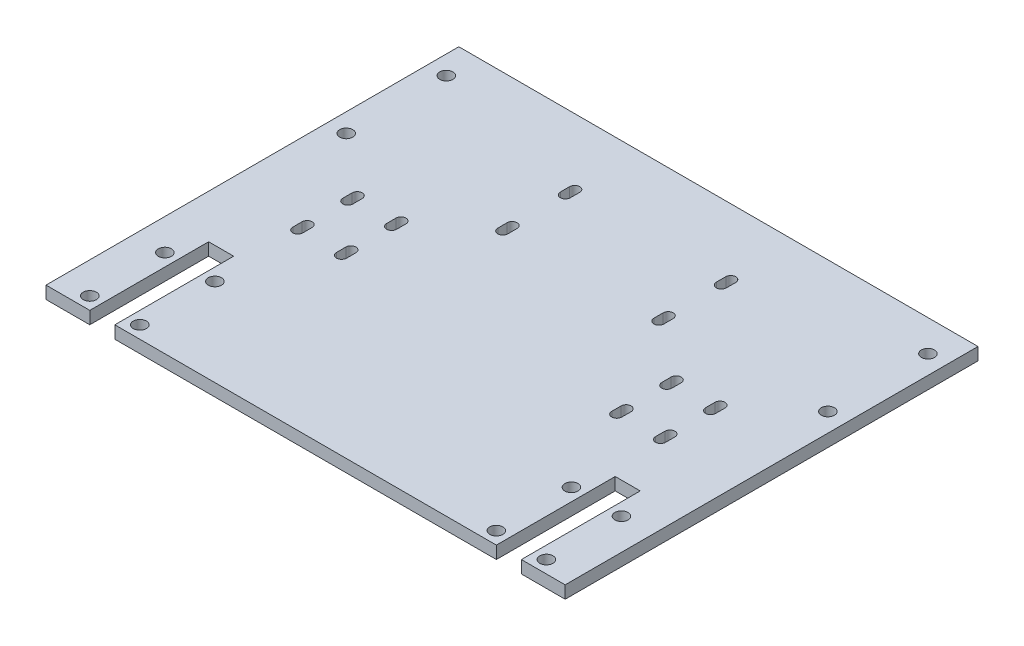
from build123d import *

# Parameters (mm, degrees)
SKETCH1_W           = 166
SKETCH1_H           = 160
SKETCH1_R           = 2.1
BOSS_EXTRUDE1_DEPTH = 4
CUT_EXTRUDE1_DEPTH  = 5
SKETCH3_R           = 2.1
SKETCH3_W           = 8
SKETCH3_H           = 44
CUT_EXTRUDE2_DEPTH  = 10
SKETCH4_W           = 166
SKETCH4_H           = 28
CUT_EXTRUDE3_DEPTH  = 10
CUT_EXTRUDE4_DEPTH  = 5


with BuildPart() as part:
    # Sketch1 → Boss-Extrude1 (new body)
    with BuildSketch(Plane(origin=(0, 0, 0), x_dir=(1, 0, 0), z_dir=(0, 1, 0))):
        Rectangle(SKETCH1_W, SKETCH1_H)
        with Locations((-77, 74)):
            Circle(SKETCH1_R, mode=Mode.SUBTRACT)
        with Locations((-77, 10)):
            Circle(SKETCH1_R, mode=Mode.SUBTRACT)
        with Locations((77, 74)):
            Circle(SKETCH1_R, mode=Mode.SUBTRACT)
        with Locations((77, 10)):
            Circle(SKETCH1_R, mode=Mode.SUBTRACT)
        with Locations((-77, 42)):
            Circle(SKETCH1_R, mode=Mode.SUBTRACT)
        with Locations((77, 42)):
            Circle(SKETCH1_R, mode=Mode.SUBTRACT)
    extrude(amount=BOSS_EXTRUDE1_DEPTH)

    # Sketch2 → Cut-Extrude1 (cut)
    with BuildSketch(Plane(origin=(0, 4, 0), x_dir=(1, 0, 0), z_dir=(0, 1, 0))):
        with BuildLine():
            Line((-59.6, -24.5), (-59.6, -21.5))
            ThreePointArc((-59.6, -21.5), (-58, -19.9), (-56.4, -21.5))
            Line((-56.4, -21.5), (-56.4, -24.5))
            ThreePointArc((-56.4, -24.5), (-58, -26.1), (-59.6, -24.5))
        make_face()
        with BuildLine():
            Line((-45.6, -24.5), (-45.6, -21.5))
            ThreePointArc((-45.6, -21.5), (-44, -19.9), (-42.4, -21.5))
            Line((-42.4, -21.5), (-42.4, -24.5))
            ThreePointArc((-42.4, -24.5), (-44, -26.1), (-45.6, -24.5))
        make_face()
        with BuildLine():
            Line((-45.6, -8.5), (-45.6, -5.5))
            ThreePointArc((-45.6, -5.5), (-44, -3.9), (-42.4, -5.5))
            Line((-42.4, -5.5), (-42.4, -8.5))
            ThreePointArc((-42.4, -8.5), (-44, -10.1), (-45.6, -8.5))
        make_face()
        with BuildLine():
            Line((-59.6, -8.5), (-59.6, -5.5))
            ThreePointArc((-59.6, -5.5), (-58, -3.9), (-56.4, -5.5))
            Line((-56.4, -5.5), (-56.4, -8.5))
            ThreePointArc((-56.4, -8.5), (-58, -10.1), (-59.6, -8.5))
        make_face()
        with BuildLine():
            Line((59.6, -8.5), (59.6, -5.5))
            ThreePointArc((59.6, -5.5), (58, -3.9), (56.4, -5.5))
            Line((56.4, -5.5), (56.4, -8.5))
            ThreePointArc((56.4, -8.5), (58, -10.1), (59.6, -8.5))
        make_face()
        with BuildLine():
            Line((45.6, -8.5), (45.6, -5.5))
            ThreePointArc((45.6, -5.5), (44, -3.9), (42.4, -5.5))
            Line((42.4, -5.5), (42.4, -8.5))
            ThreePointArc((42.4, -8.5), (44, -10.1), (45.6, -8.5))
        make_face()
        with BuildLine():
            Line((45.6, -24.5), (45.6, -21.5))
            ThreePointArc((45.6, -21.5), (44, -19.9), (42.4, -21.5))
            Line((42.4, -21.5), (42.4, -24.5))
            ThreePointArc((42.4, -24.5), (44, -26.1), (45.6, -24.5))
        make_face()
        with BuildLine():
            Line((59.6, -24.5), (59.6, -21.5))
            ThreePointArc((59.6, -21.5), (58, -19.9), (56.4, -21.5))
            Line((56.4, -21.5), (56.4, -24.5))
            ThreePointArc((56.4, -24.5), (58, -26.1), (59.6, -24.5))
        make_face()
    extrude(amount=-CUT_EXTRUDE1_DEPTH, mode=Mode.SUBTRACT)

    # Sketch3 → Cut-Extrude2 (cut)
    with BuildSketch(Plane(origin=(0, 4, 0), x_dir=(1, 0, 0), z_dir=(0, 1, 0))):
        with Locations((-73, -76)):
            Circle(SKETCH3_R)
        with Locations((-57, -76)):
            Circle(SKETCH3_R)
        with Locations((-57, -52)):
            Circle(SKETCH3_R)
        with Locations((-73, -52)):
            Circle(SKETCH3_R)
        with Locations((73, -52)):
            Circle(SKETCH3_R)
        with Locations((57, -52)):
            Circle(SKETCH3_R)
        with Locations((57, -76)):
            Circle(SKETCH3_R)
        with Locations((73, -76)):
            Circle(SKETCH3_R)
        with Locations((-65, -64)):
            Rectangle(SKETCH3_W, SKETCH3_H)
        with Locations((65, -64)):
            Rectangle(SKETCH3_W, SKETCH3_H)
    extrude(amount=-CUT_EXTRUDE2_DEPTH, mode=Mode.SUBTRACT)

    # Sketch4 → Cut-Extrude3 (cut)
    with BuildSketch(Plane(origin=(0, 4, 0), x_dir=(1, 0, 0), z_dir=(0, 1, 0))):
        with Locations((0, 66)):
            Rectangle(SKETCH4_W, SKETCH4_H)
    extrude(amount=-CUT_EXTRUDE3_DEPTH, mode=Mode.SUBTRACT)

    # Sketch5 → Cut-Extrude4 (cut, through all)
    with BuildSketch(Plane(origin=(0, 4, 0), x_dir=(1, 0, 0), z_dir=(0, 1, 0))):
        with BuildLine():
            Line((-26.55, 28), (-26.55, 31))
            ThreePointArc((-26.55, 31), (-24.95, 32.6), (-23.35, 31))
            Line((-23.35, 31), (-23.35, 28))
            ThreePointArc((-23.35, 28), (-24.95, 26.4), (-26.55, 28))
        make_face()
        with BuildLine():
            Line((23.35, 28), (23.35, 31))
            ThreePointArc((23.35, 31), (24.95, 32.6), (26.55, 31))
            Line((26.55, 31), (26.55, 28))
            ThreePointArc((26.55, 28), (24.95, 26.4), (23.35, 28))
        make_face()
        with BuildLine():
            Line((23.35, 8), (23.35, 11))
            ThreePointArc((23.35, 11), (24.95, 12.6), (26.55, 11))
            Line((26.55, 11), (26.55, 8))
            ThreePointArc((26.55, 8), (24.95, 6.4), (23.35, 8))
        make_face()
        with BuildLine():
            Line((-26.55, 8), (-26.55, 11))
            ThreePointArc((-26.55, 11), (-24.95, 12.6), (-23.35, 11))
            Line((-23.35, 11), (-23.35, 8))
            ThreePointArc((-23.35, 8), (-24.95, 6.4), (-26.55, 8))
        make_face()
    extrude(amount=-CUT_EXTRUDE4_DEPTH, mode=Mode.SUBTRACT)


solid = part.part
